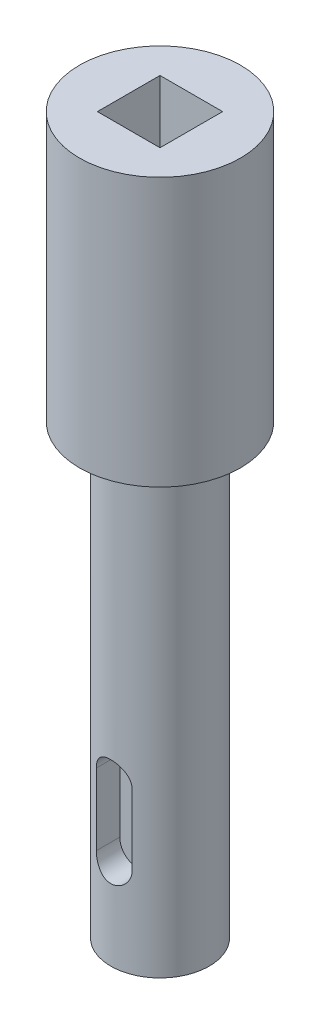
from build123d import *

# Parameters (mm, degrees)
SKETCH_2_W          = 7
SKETCH_2_H          = 7
CUT_EXTRUDE_1_DEPTH = 20
CUT_EXTRUDE_2_DEPTH = 3


with BuildPart() as part:
    # 草图1 → 旋转1 (revolve)
    with BuildSketch(Plane.XY):
        Polygon((0, 0), (-5.5, 0), (-5.5, 50), (-9, 50), (-9, 80), (0, 80), align=None)
    revolve(axis=Axis((0, 0, 0), (0, 1, 0)))

    # 草图2 → 切除-拉伸1 (cut)
    with BuildSketch(Plane(origin=(0, 80, 0), x_dir=(1, 0, 0), z_dir=(0, 1, 0))):
        Rectangle(SKETCH_2_W, SKETCH_2_H)
    extrude(amount=-CUT_EXTRUDE_1_DEPTH, mode=Mode.SUBTRACT)

    # 草图4 → 切除-拉伸2 (cut)
    with BuildSketch(Plane.XY.offset(5.5)):
        with BuildLine():
            Line((-2, 10), (-2, 18))
            ThreePointArc((-2, 18), (0, 20), (2, 18))
            Line((2, 18), (2, 10))
            ThreePointArc((2, 10), (0, 8), (-2, 10))
        make_face()
    extrude(amount=-CUT_EXTRUDE_2_DEPTH, mode=Mode.SUBTRACT)


solid = part.part
